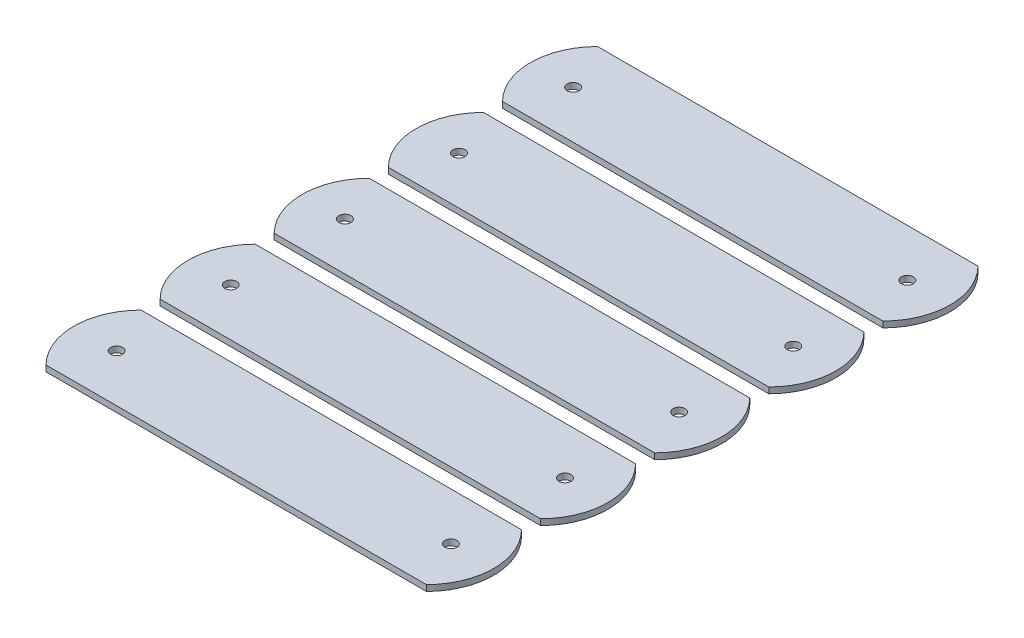
from build123d import *

# Parameters (mm, degrees)
SKETCH1_W           = 101.6
SKETCH1_H           = 25.4
SKETCH1_R           = 1.6002
BOSS_EXTRUDE1_DEPTH = 0.79375
LPATTERN1_COUNT     = 5
LPATTERN1_PITCH     = 30.48


with BuildPart() as part:
    # Sketch1 → Boss-Extrude1 (new body, symmetric)
    with BuildSketch(Plane(origin=(0, 0, 0), x_dir=(1, 0, 0), z_dir=(0, 1, 0))):
        Rectangle(SKETCH1_W, SKETCH1_H)
        with Locations((-44.637105686, 0)):
            Circle(SKETCH1_R, mode=Mode.SUBTRACT)
        with Locations((44.637105686, 0)):
            Circle(SKETCH1_R, mode=Mode.SUBTRACT)
        with BuildLine():
            ThreePointArc((-50.8, -12.7), (-56.060512242, 0), (-50.8, 12.7))
            Line((-50.8, 12.7), (-50.8, -12.7))
        make_face()
        with BuildLine():
            ThreePointArc((50.8, 12.7), (56.060512242, 0), (50.8, -12.7))
            Line((50.8, -12.7), (50.8, 12.7))
        make_face()
    extrude(amount=BOSS_EXTRUDE1_DEPTH, both=True)


with BuildPart() as lpattern1_1:
    # LPattern1: pattern copy
    add(part.part.moved(Location(Vector(0, 0, -1) * (1 * LPATTERN1_PITCH))))


with BuildPart() as lpattern1_2:
    # LPattern1: pattern copy
    add(part.part.moved(Location(Vector(0, 0, -1) * (2 * LPATTERN1_PITCH))))


with BuildPart() as lpattern1_3:
    # LPattern1: pattern copy
    add(part.part.moved(Location(Vector(0, 0, -1) * (3 * LPATTERN1_PITCH))))


with BuildPart() as lpattern1_4:
    # LPattern1: pattern copy
    add(part.part.moved(Location(Vector(0, 0, -1) * (4 * LPATTERN1_PITCH))))


solid = Compound([part.part, lpattern1_1.part, lpattern1_2.part, lpattern1_3.part, lpattern1_4.part])
